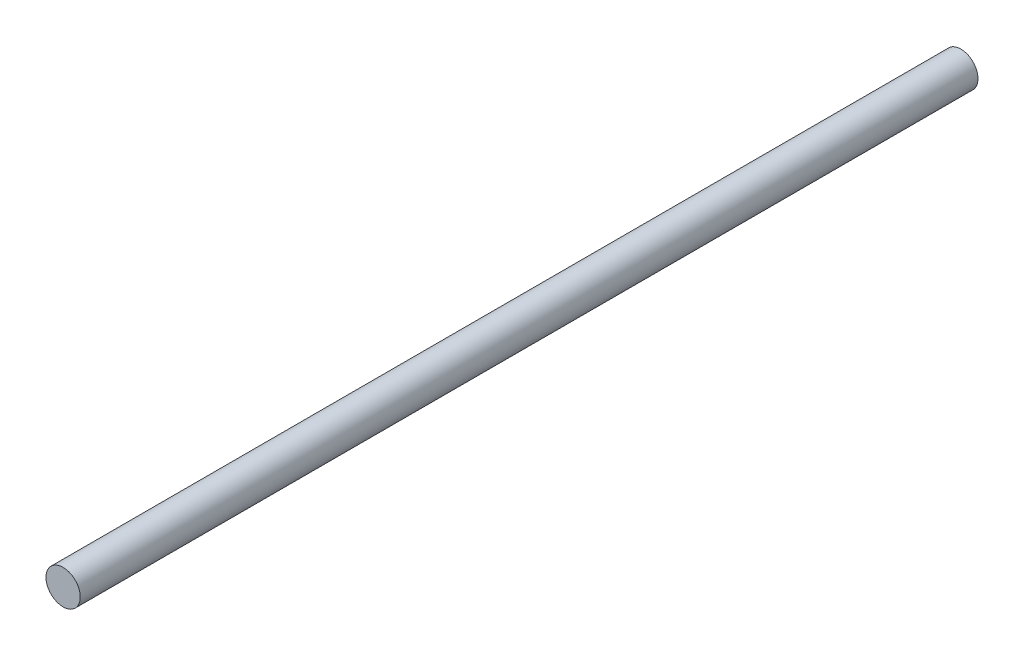
from build123d import *

# Parameters (mm, degrees)
SKETCH1_R           = 0.5
BOSS_EXTRUDE1_DEPTH = 26.2


with BuildPart() as part:
    # Sketch1 → Boss-Extrude1 (new body)
    with BuildSketch(Plane.XY):
        Circle(SKETCH1_R)
    extrude(amount=BOSS_EXTRUDE1_DEPTH)


solid = part.part
